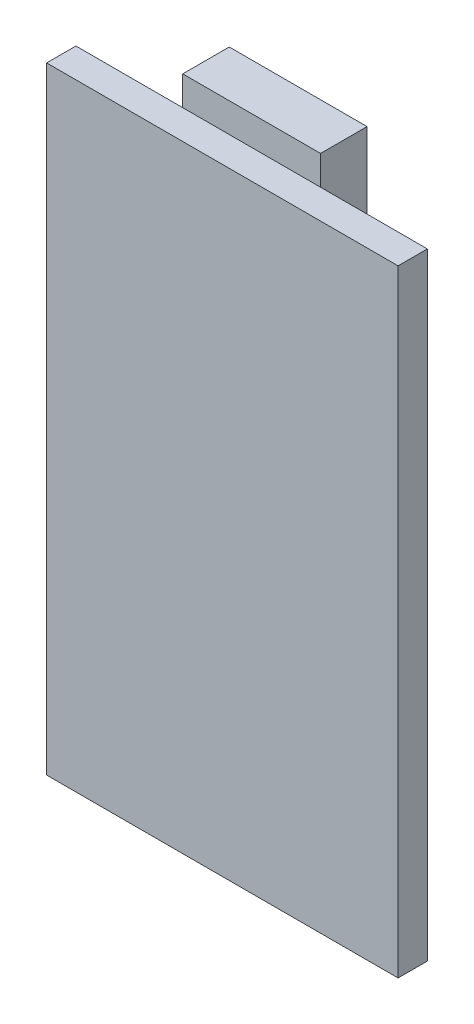
from build123d import *

# Parameters (mm, degrees)
SKETCH1_W           = 20.4
SKETCH1_H           = 35.8
BOSS_EXTRUDE1_DEPTH = 1.7
SKETCH2_W           = 8
SKETCH2_H           = 5.8
BOSS_EXTRUDE2_DEPTH = 2.7


with BuildPart() as part:
    # Sketch1 → Boss-Extrude1 (new body)
    with BuildSketch(Plane.XY):
        with Locations((0, -17.9)):
            Rectangle(SKETCH1_W, SKETCH1_H)
    extrude(amount=-BOSS_EXTRUDE1_DEPTH)

    # Sketch2 → Boss-Extrude2 (add)
    with BuildSketch(Plane(origin=(0, 0, -1.7), x_dir=(-1, 0, 0), z_dir=(0, 0, -1))):
        with Locations((0, -1.2)):
            Rectangle(SKETCH2_W, SKETCH2_H)
    extrude(amount=BOSS_EXTRUDE2_DEPTH)


solid = part.part
